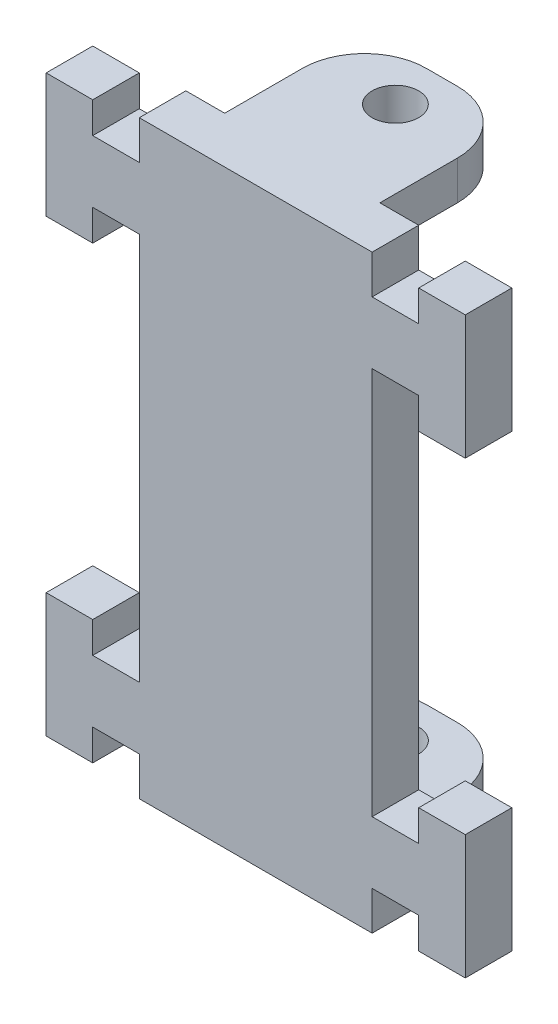
from build123d import *

# Parameters (mm, degrees)
SKETCH_1_W            = 15
SKETCH_1_H            = 38
EXTRUDE_1_DEPTH       = 3
EXTRUDE_4_DEPTH       = 3
SKETCH_6_W            = 10
SKETCH_6_H            = 2.5
EXTRUDE_5_DEPTH       = 9
HOLE_WIZARD_3_0_3_1_D = 3
FILLET_1_R            = 4


with BuildPart() as part:
    # 스케치1 → 보스-돌출1 (new body)
    with BuildSketch(Plane.XY):
        Rectangle(SKETCH_1_W, SKETCH_1_H)
    extrude(amount=EXTRUDE_1_DEPTH)

    # 스케치5 → 보스-돌출4 (add)
    with BuildSketch(Plane(origin=(0, 0, 0), x_dir=(-1, 0, 0), z_dir=(0, 0, -1))):
        Polygon((-7.5, 16.5), (-10.5, 16.5), (-10.5, 18.5), (-13.5, 18.5), (-13.5, 10.5), (-10.5, 10.5), (-10.5, 12.5), (-7.5, 12.5), align=None)
        Polygon((7.5, 16.5), (7.5, 12.5), (10.5, 12.5), (10.5, 10.5), (13.5, 10.5), (13.5, 18.5), (10.5, 18.5), (10.5, 16.5), align=None)
        Polygon((7.5, -16.5), (10.5, -16.5), (10.5, -18.5), (13.5, -18.5), (13.5, -10.5), (10.5, -10.5), (10.5, -12.5), (7.5, -12.5), align=None)
        Polygon((-7.5, -16.5), (-7.5, -12.5), (-10.5, -12.5), (-10.5, -10.5), (-13.5, -10.5), (-13.5, -18.5), (-10.5, -18.5), (-10.5, -16.5), align=None)
    extrude(amount=-EXTRUDE_4_DEPTH)

    # 스케치6 → 보스-돌출5 (add)
    with BuildSketch(Plane(origin=(0, 0, 0), x_dir=(-1, 0, 0), z_dir=(0, 0, -1))):
        with Locations((0, 17.75)):
            Rectangle(SKETCH_6_W, SKETCH_6_H)
        with Locations((0, -17.75)):
            Rectangle(SKETCH_6_W, SKETCH_6_H)
    extrude(amount=EXTRUDE_5_DEPTH)

    # Ø3.0 (3) 지름 구멍1 (through all)
    with Locations(Plane(origin=(0, 19, 0), x_dir=(1, 0, 0), z_dir=(0, 1, 0))):
        with Locations((0, 6)):
            Hole(HOLE_WIZARD_3_0_3_1_D / 2)

    # 필렛1
    fillet_1_edges = [part.edges().sort_by_distance(p)[0] for p in [
        (5, 17.75, -9),
        (-5, 17.75, -9),
        (-5, -17.75, -9),
        (5, -17.75, -9),
    ]]
    fillet(fillet_1_edges, radius=FILLET_1_R)


solid = part.part
